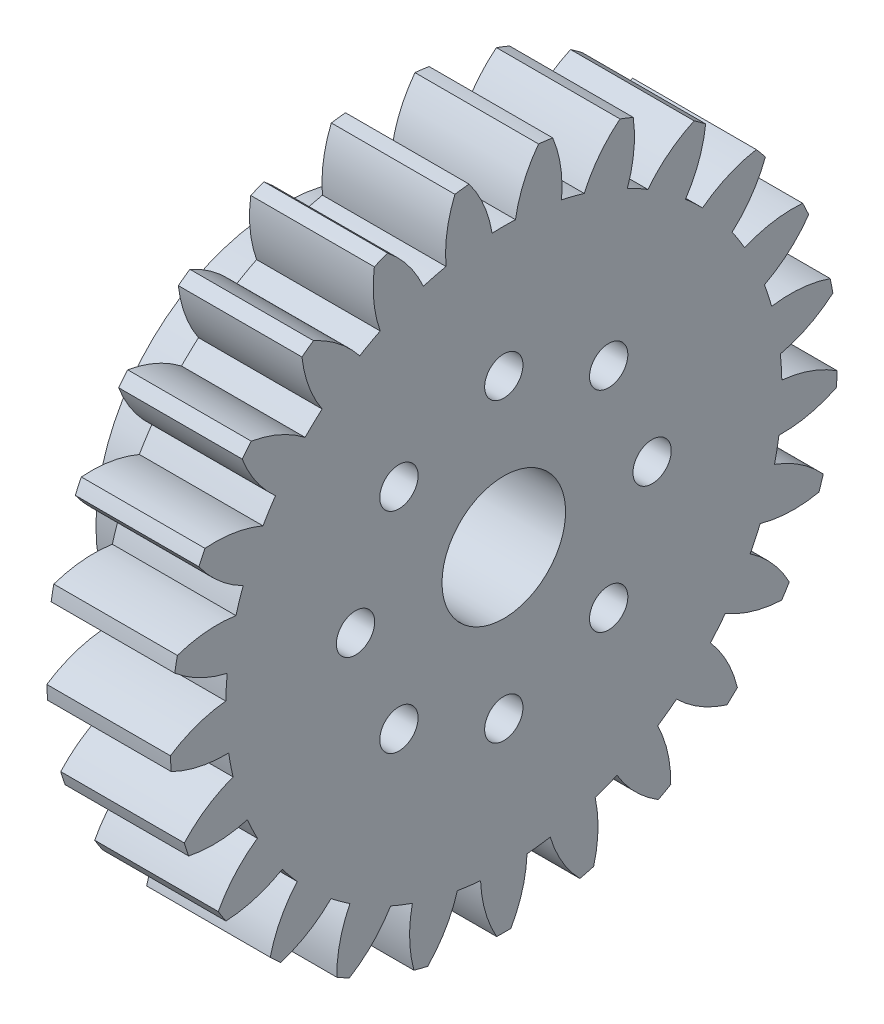
from build123d import *

# Parameters (mm, degrees)
BASPROSKE_W                                       = 10
BASPROSKE_H                                       = 27
TOOTHCUT_DEPTH                                    = 40.471508712
TEETHCUTS_COUNT                                   = 25
TEETHCUTS_ANGLE                                   = 345.6
BORSKE_R                                          = 5
BORE_DEPTH                                        = 50.0000508
SKETCH2_R                                         = 15
BOSS_EXTRUDE1_DEPTH                               = 8
SKETCH3_R                                         = 6
CUT_EXTRUDE2_DEPTH                                = 8
CSK_FOR_M2_5_FLAT_HEAD_MACHINE_SCREW1_D           = 3.1
CSK_FOR_M2_5_FLAT_HEAD_MACHINE_SCREW1_DEPTH       = 18
CSK_FOR_M2_5_FLAT_HEAD_MACHINE_SCREW1_CSINK_D     = 5.5
CSK_FOR_M2_5_FLAT_HEAD_MACHINE_SCREW1_CSINK_ANGLE = 90
CSK_FOR_M2_5_FLAT_HEAD_MACHINE_SCREW1_TIP         = 0.931333959


with BuildPart() as part:
    # BasProSke → Base-Revolve (revolve)
    with BuildSketch(Plane(origin=(0, 0, 0), x_dir=(1, 0, 0), z_dir=(0, 1, 0)), mode=Mode.PRIVATE) as base_revolve_sk:
        with Locations((5, 13.5)):
            Rectangle(BASPROSKE_W, BASPROSKE_H)
    revolve(base_revolve_sk.sketch.rotate(Axis((-10, 0, 0), (1, 0, 0)), 180), axis=Axis((-10, 0, 0), (1, 0, 0)))

    # TooCutSke → ToothCut (cut, through all)
    with BuildSketch(Plane(origin=(0, 0, 0), x_dir=(0, 0, -1), z_dir=(1, 0, 0))):
        with BuildLine():
            ThreePointArc((0.946154762, 22.479096783), (0, 22.499), (-0.946154762, 22.479096783))
            ThreePointArc((-0.946154762, 22.479096783), (-1.62094792, 24.792268013), (-2.829470045, 26.876873784))
            ThreePointArc((-2.829470045, 26.876873784), (0, 27.0254), (2.829470045, 26.876873784))
            ThreePointArc((2.829470045, 26.876873784), (1.62094792, 24.792268013), (0.946154762, 22.479096783))
        make_face()
    toothcut = extrude(amount=TOOTHCUT_DEPTH, mode=Mode.SUBTRACT)

    # TeethCuts: ToothCut ×25 about axis
    teethcuts_axis = Axis((-10, 0, 0), (1, 0, 0))
    for i in range(1, TEETHCUTS_COUNT):
        add(toothcut.rotate(teethcuts_axis, i * TEETHCUTS_ANGLE / (TEETHCUTS_COUNT - 1)), mode=Mode.SUBTRACT)

    # BorSke → Bore (cut, symmetric)
    with BuildSketch(Plane(origin=(0, 0, 0), x_dir=(0, 0, -1), z_dir=(1, 0, 0))):
        with Locations(Location((0, 0, 0), (0, 0, 180))):
            Circle(BORSKE_R)
    extrude(amount=BORE_DEPTH, both=True, mode=Mode.SUBTRACT)

    # Sketch2 → Boss-Extrude1 (add)
    with BuildSketch(Plane.ZY):
        with Locations(Location((0, 0, 0), (0, 0, 180))):
            Circle(SKETCH2_R)
    extrude(amount=BOSS_EXTRUDE1_DEPTH)

    # Sketch3 → Cut-Extrude2 (cut)
    with BuildSketch(Plane.ZY.offset(8)):
        Circle(SKETCH3_R)
    extrude(amount=-CUT_EXTRUDE2_DEPTH, mode=Mode.SUBTRACT)

    # CSK for M2.5 Flat Head Machine Screw1
    with Locations(Plane.ZY.offset(8)):
        with Locations((12, 0), (8.485281374, -8.485281374), (0, -12), (-8.485281374, -8.485281374), (-12, 0), (-8.485281374, 8.485281374), (0, 12), (8.485281374, 8.485281374), (0, 0)):
            CounterSinkHole(CSK_FOR_M2_5_FLAT_HEAD_MACHINE_SCREW1_D / 2, CSK_FOR_M2_5_FLAT_HEAD_MACHINE_SCREW1_CSINK_D / 2, depth=CSK_FOR_M2_5_FLAT_HEAD_MACHINE_SCREW1_DEPTH, counter_sink_angle=CSK_FOR_M2_5_FLAT_HEAD_MACHINE_SCREW1_CSINK_ANGLE)
            with Locations((0, 0, -(CSK_FOR_M2_5_FLAT_HEAD_MACHINE_SCREW1_DEPTH + CSK_FOR_M2_5_FLAT_HEAD_MACHINE_SCREW1_TIP / 2))):  # 118° drill point
                Cone(0, CSK_FOR_M2_5_FLAT_HEAD_MACHINE_SCREW1_D / 2, CSK_FOR_M2_5_FLAT_HEAD_MACHINE_SCREW1_TIP, mode=Mode.SUBTRACT)


solid = part.part
